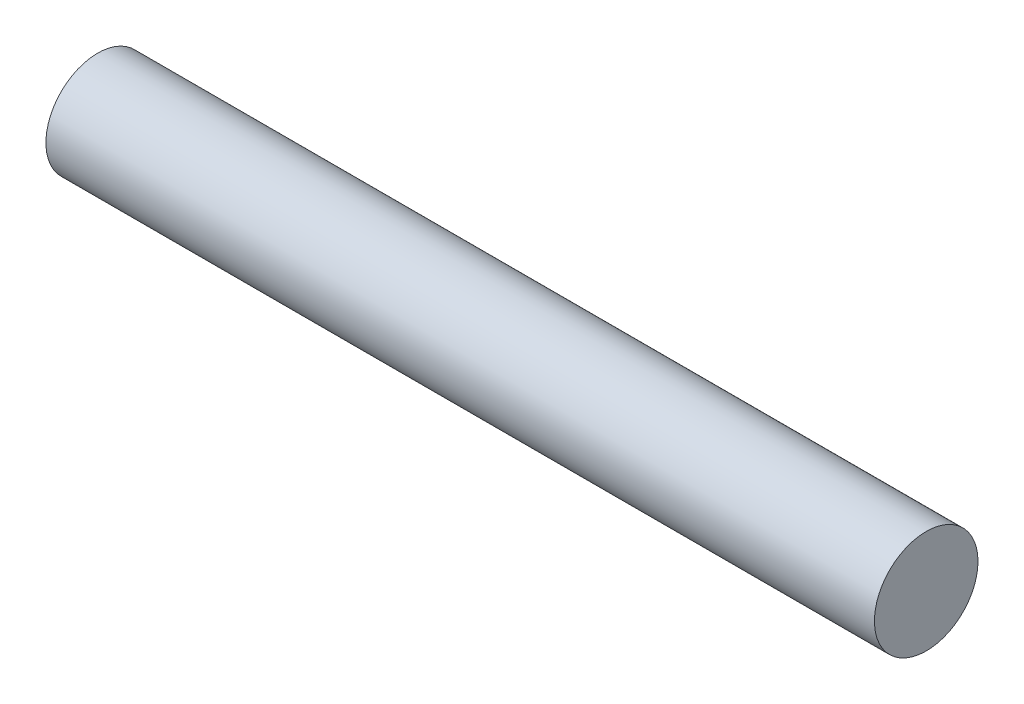
from build123d import *

# Parameters (mm, degrees)
SKETCH1_R           = 5
BOSS_EXTRUDE1_DEPTH = 80


with BuildPart() as part:
    # Sketch1 → Boss-Extrude1 (new body)
    with BuildSketch(Plane(origin=(0, 0, 0), x_dir=(0, 0, -1), z_dir=(1, 0, 0))):
        Circle(SKETCH1_R)
    extrude(amount=BOSS_EXTRUDE1_DEPTH)


solid = part.part
